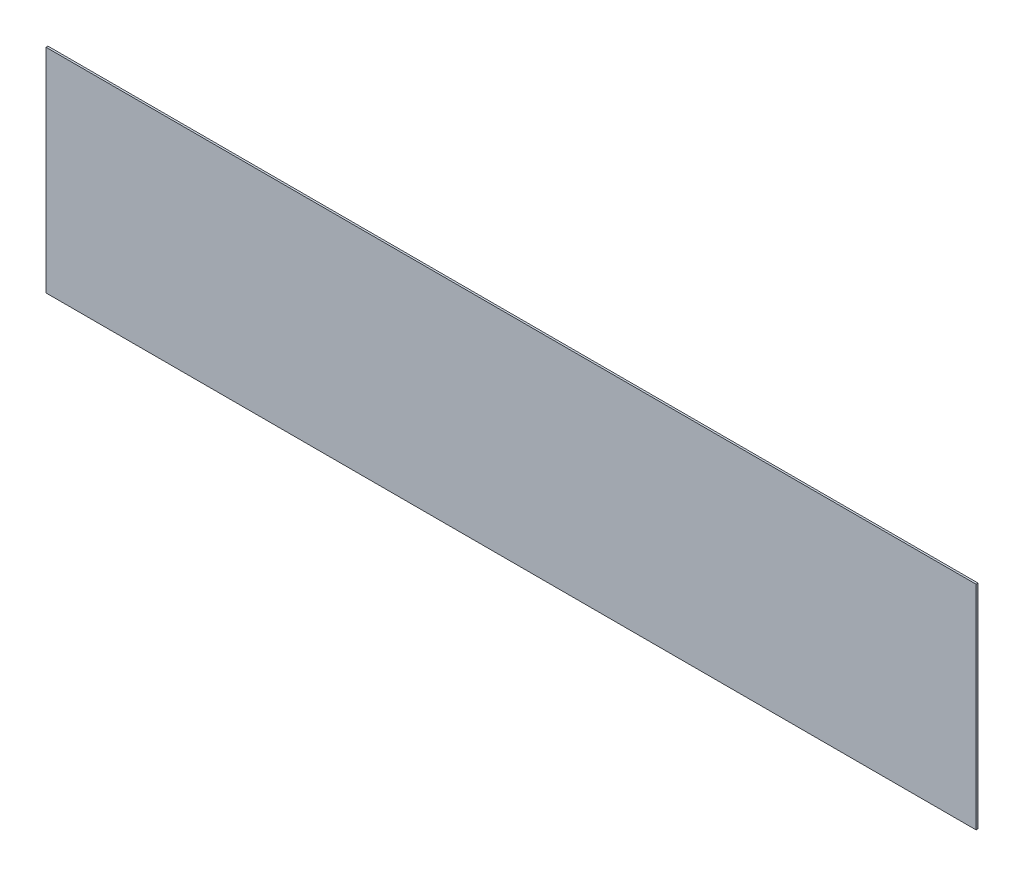
from build123d import *

# Parameters (mm, degrees)
SKETCH1_W           = 59.944
SKETCH1_H           = 13.716
BOSS_EXTRUDE1_DEPTH = 0.127


with BuildPart() as part:
    # Sketch1 → Boss-Extrude1 (new body)
    with BuildSketch(Plane.XY):
        with Locations((-137.237805359, -177.626597764)):
            Rectangle(SKETCH1_W, SKETCH1_H)
    extrude(amount=BOSS_EXTRUDE1_DEPTH)


solid = part.part
